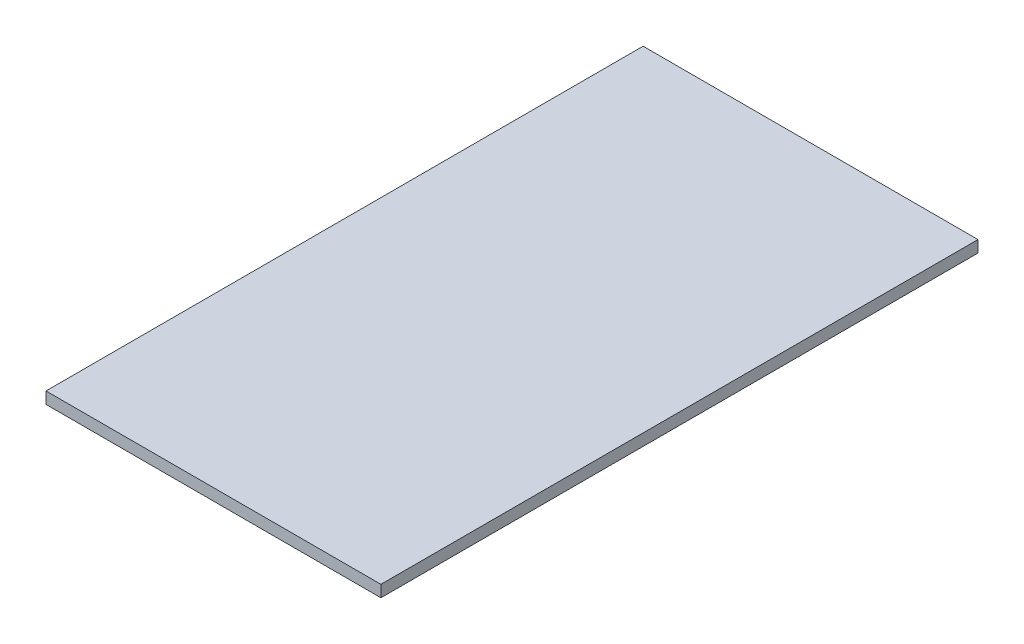
from build123d import *

# Parameters (mm, degrees)
SKETCH_1_W      = 516
SKETCH_1_H      = 920
EXTRUDE_1_DEPTH = 18


with BuildPart() as part:
    # Эскиз1 → Бобышка-Вытянуть1 (new body)
    with BuildSketch(Plane(origin=(0, 0, 0), x_dir=(1, 0, 0), z_dir=(0, 1, 0))):
        Rectangle(SKETCH_1_W, SKETCH_1_H)
    extrude(amount=EXTRUDE_1_DEPTH)


solid = part.part
